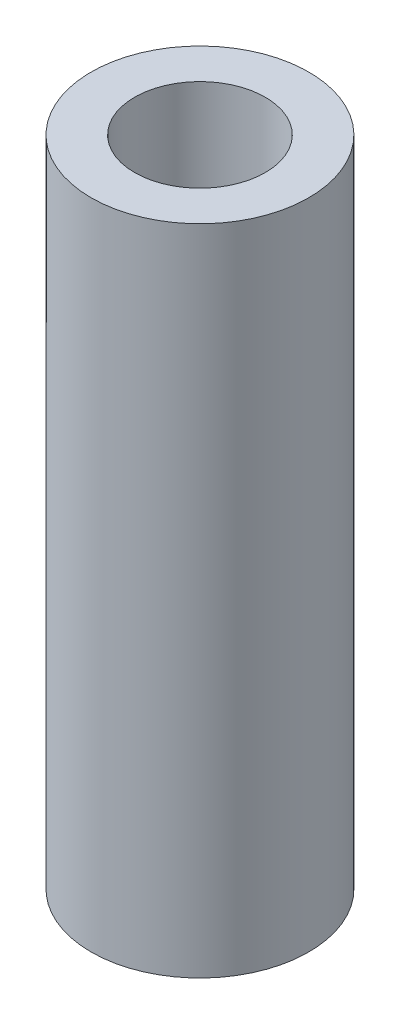
from build123d import *

# Parameters (mm, degrees)
SKETCH1_R           = 2.5
SKETCH1_R_2         = 1.5
BOSS_EXTRUDE1_DEPTH = 15


with BuildPart() as part:
    # Sketch1 → Boss-Extrude1 (new body)
    with BuildSketch(Plane(origin=(0, 0, 0), x_dir=(1, 0, 0), z_dir=(0, 1, 0))):
        Circle(SKETCH1_R)
        Circle(SKETCH1_R_2, mode=Mode.SUBTRACT)
    extrude(amount=BOSS_EXTRUDE1_DEPTH)


solid = part.part
